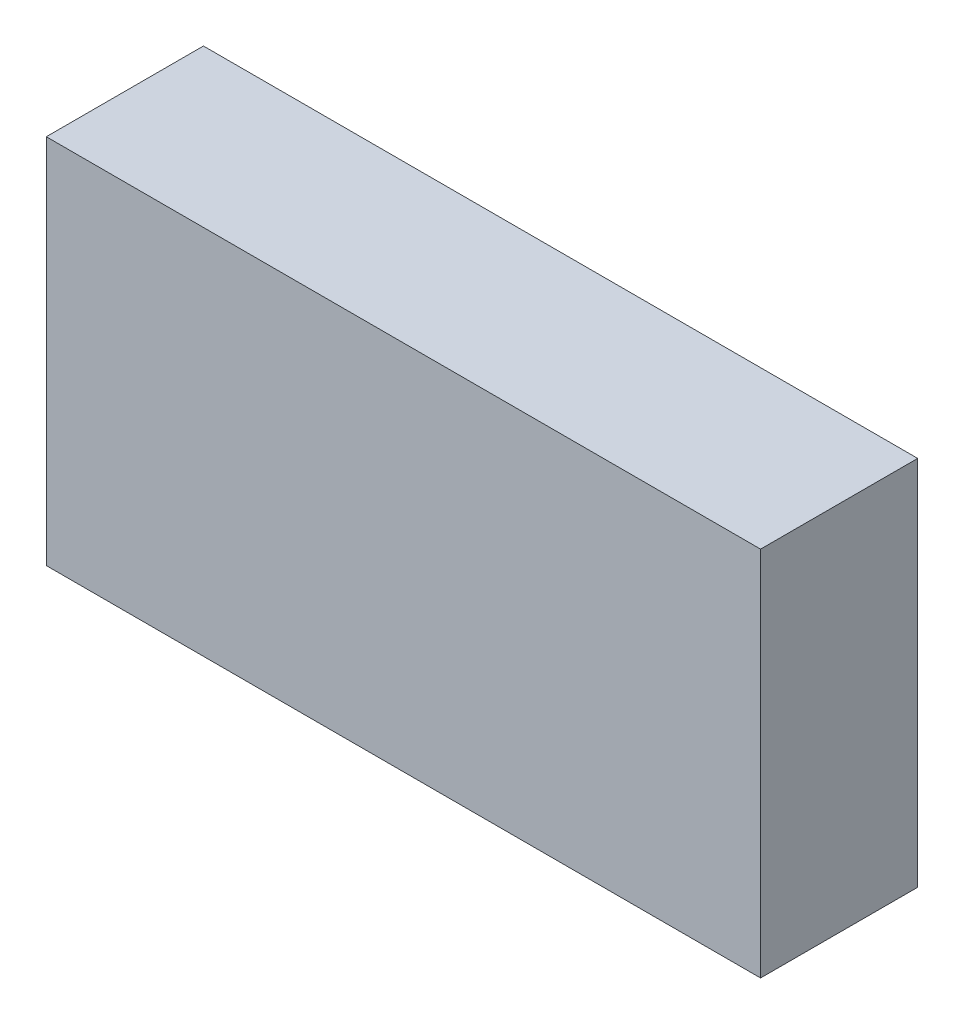
from build123d import *

# Parameters (mm, degrees)
SKETCH_1_W      = 50
SKETCH_1_H      = 26
EXTRUDE_1_DEPTH = 11


with BuildPart() as part:
    # Эскиз1 → Бобышка-Вытянуть1 (new body)
    with BuildSketch(Plane.XY):
        with Locations((11.572736916, 53.63430368)):
            Rectangle(SKETCH_1_W, SKETCH_1_H)
    extrude(amount=EXTRUDE_1_DEPTH)


solid = part.part
